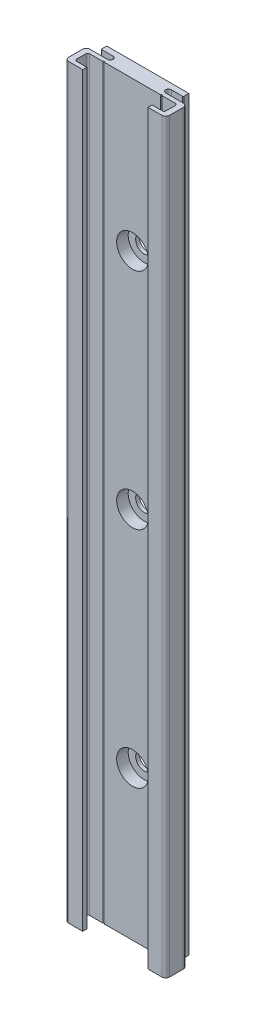
from build123d import *

# Parameters (mm, degrees)
BOSS_EXTRU_1_DEPTH                                 = 200
ENL_V_MAT_EXTRU_1_DEPTH                            = 201
DIAM_TRE_DU_PER_AGE_0_4_0_4_1_D                    = 0.4
DIAM_TRE_DU_PER_AGE_0_4_0_4_1_DEPTH                = 200
CHAMBRAGE_POUR_VIS_T_TE_HEXAGONALE_M41_D           = 4.5
CHAMBRAGE_POUR_VIS_T_TE_HEXAGONALE_M41_CBORE_D     = 8.5
CHAMBRAGE_POUR_VIS_T_TE_HEXAGONALE_M41_CBORE_DEPTH = 3.1
CONG_1_R                                           = 0.2
CONG_2_R                                           = 0.5
CONG_3_R                                           = 1


with BuildPart() as part:
    # Esquisse1 → Boss.-Extru.1 (new body)
    with BuildSketch(Plane.XZ.offset(100)):
        with BuildLine():
            Line((-11, 0), (11, 0))
            Line((11, 0), (11, 1.5))
            Line((11, 1.5), (7.8, 1.5))
            ThreePointArc((7.8, 1.5), (7.05, 2.25), (7.8, 3))
            Line((7.8, 3), (13.5, 3))
            Line((13.5, 3), (13.5, 8.7))
            Line((13.5, 8.7), (-13.5, 8.7))
            Line((-13.5, 8.7), (-13.5, 3))
            Line((-13.5, 3), (-7.8, 3))
            ThreePointArc((-7.8, 3), (-7.05, 2.25), (-7.8, 1.5))
            Line((-7.8, 1.5), (-11, 1.5))
            Line((-11, 1.5), (-11, 0))
        make_face()
    extrude(amount=-BOSS_EXTRU_1_DEPTH)

    # Esquisse2 → Enlèv. mat.-Extru.1 (cut, through all)
    with BuildSketch(Plane(origin=(0, 100, 0), x_dir=(-1, 0, 0), z_dir=(0, 1, 0))):
        Polygon((8.75, 8.7), (-8.75, 8.7), (-8.75, 7.6), (-12, 7.6), (-12, 4.1), (12, 4.1), (12, 7.6), (8.75, 7.6), align=None)
    extrude(amount=-ENL_V_MAT_EXTRU_1_DEPTH, mode=Mode.SUBTRACT)

    # Diamètre du perçage Ø0.4 (0.4)1
    with Locations(Plane(origin=(0, -100, 0), x_dir=(-1, 0, 0), z_dir=(0, -1, 0))):
        with Locations((-7.75, -4.1), (7.75, -4.1)):
            Hole(DIAM_TRE_DU_PER_AGE_0_4_0_4_1_D / 2, depth=DIAM_TRE_DU_PER_AGE_0_4_0_4_1_DEPTH)

    # Chambrage pour vis à tête hexagonale M41 (through all)
    with Locations(Plane.XY.offset(4.1)):
        with Locations((0, -60), (0, 0), (0, 60)):
            CounterBoreHole(CHAMBRAGE_POUR_VIS_T_TE_HEXAGONALE_M41_D / 2, CHAMBRAGE_POUR_VIS_T_TE_HEXAGONALE_M41_CBORE_D / 2, CHAMBRAGE_POUR_VIS_T_TE_HEXAGONALE_M41_CBORE_DEPTH)

    # Congé1
    cong_1_edges = [part.edges().sort_by_distance(p)[0] for p in [
        (-11, 0, 1.5),
        (11, 0, 1.5),
    ]]
    fillet(cong_1_edges, radius=CONG_1_R)

    # Congé2
    cong_2_edges = [part.edges().sort_by_distance(p)[0] for p in [
        (-12, 0, 7.6),
        (-12, 0, 4.1),
        (12, 0, 4.1),
        (12, 0, 7.6),
    ]]
    fillet(cong_2_edges, radius=CONG_2_R)

    # Congé3
    cong_3_edges = [part.edges().sort_by_distance(p)[0] for p in [
        (-13.5, 0, 3),
        (-13.5, 0, 8.7),
        (13.5, 0, 8.7),
        (13.5, 0, 3),
    ]]
    fillet(cong_3_edges, radius=CONG_3_R)


solid = part.part
